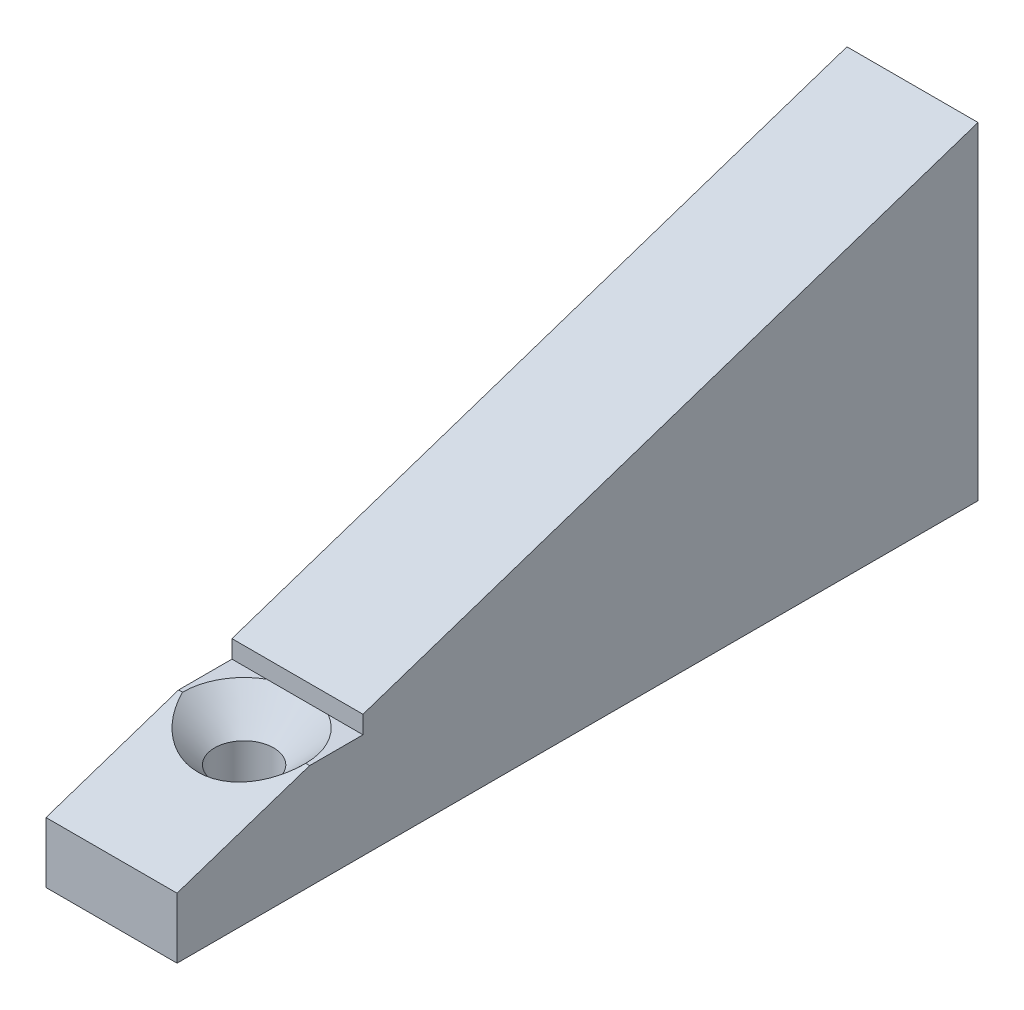
from build123d import *

# Parameters (mm, degrees)
BOSS_EXTRUDE1_DEPTH       = 10
F_4_0MM_DOWEL_HOLE1_D     = 4
F_4_0MM_DOWEL_HOLE1_DEPTH = 10
F_4_0MM_DOWEL_HOLE1_TIP   = 1.201721238


with BuildPart() as part:
    # Sketch1 → Boss-Extrude1 (new body)
    with BuildSketch(Plane(origin=(0, 0, 0), x_dir=(0, 0, -1), z_dir=(1, 0, 0))):
        Polygon((-18.718400177, 4.62678414), (-8.598752597, 8), (-4.529205873, 8), (-4.529205873, 9.356515575), (42.401247403, 25), (42.401247403, 0), (-18.718400177, 0), align=None)
    extrude(amount=BOSS_EXTRUDE1_DEPTH)

    # Sketch9 → CSK for M4 Flat Head Machine Screw2 (revolve, cut)
    with BuildSketch(Plane(origin=(5, 8, 8.598752597), x_dir=(0, 0, 1), z_dir=(1, 0, 0))):
        Polygon((0, 0), (0, 11.351936393), (2.25, 10), (2.25, 2.45), (4.7, 0), align=None)
    revolve(axis=Axis((5, 14.35, 8.598752597), (0, -1, 0)), mode=Mode.SUBTRACT)

    # Ø4.0mm Dowel Hole1
    with Locations(Plane(origin=(5, 18, -42.401247403), x_dir=(0, -1, 0), z_dir=(0, 0, -1))):
        with Locations((0, 0), (11, 0)):
            Hole(F_4_0MM_DOWEL_HOLE1_D / 2, depth=F_4_0MM_DOWEL_HOLE1_DEPTH)
            with Locations((0, 0, -(F_4_0MM_DOWEL_HOLE1_DEPTH + F_4_0MM_DOWEL_HOLE1_TIP / 2))):  # 118° drill point
                Cone(0, F_4_0MM_DOWEL_HOLE1_D / 2, F_4_0MM_DOWEL_HOLE1_TIP, mode=Mode.SUBTRACT)


solid = part.part
